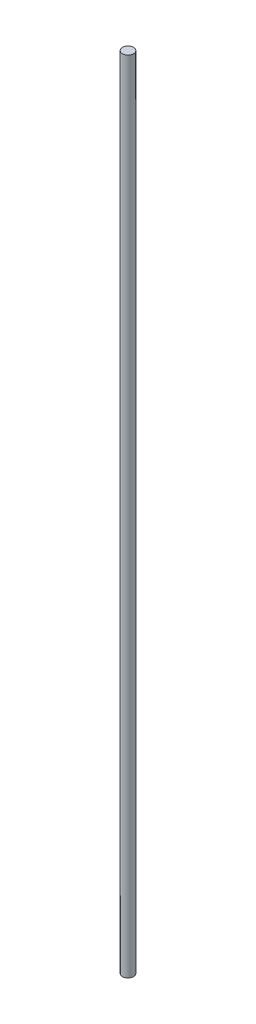
from build123d import *

# Parameters (mm, degrees)
SKETCH1_R           = 2.5
BOSS_EXTRUDE1_DEPTH = 360


with BuildPart() as part:
    # Sketch1 → Boss-Extrude1 (new body)
    with BuildSketch(Plane(origin=(0, 0, 0), x_dir=(1, 0, 0), z_dir=(0, 1, 0))):
        Circle(SKETCH1_R)
    extrude(amount=BOSS_EXTRUDE1_DEPTH)


solid = part.part
